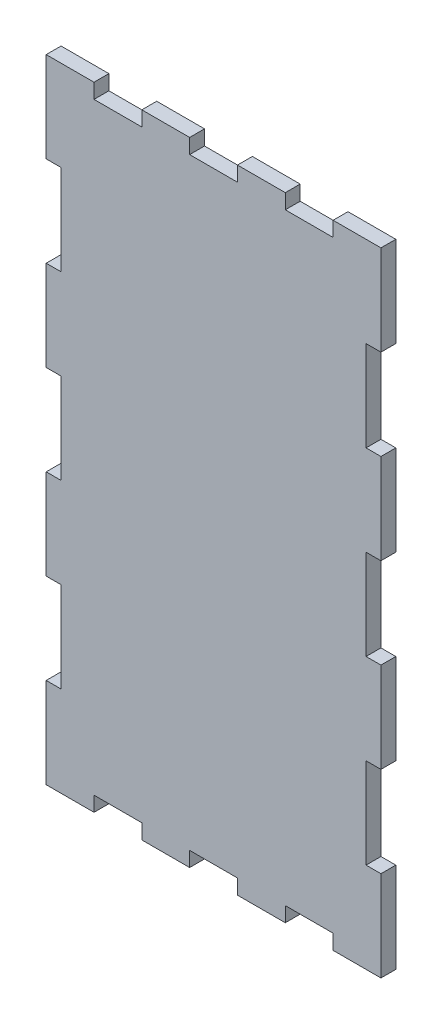
from build123d import *

# Parameters (mm, degrees)
BUITENAFMETING_RECHTHOEK_W  = 90
BUITENAFMETING_RECHTHOEK_H  = 170
PLAAT_DEPTH                 = 4
TAND_HOR_W                  = 12.857142857
TAND_HOR_H                  = 4
TAND_BOVEN_DEPTH            = 5
TANDEN_PATROON_BOVEN_COUNT  = 3
TANDEN_PATROON_BOVEN_PITCH  = 25.714285714
TAND_VER_W                  = 4
TAND_VER_H                  = 24.285714285
TAND_LINKS_DEPTH            = 5
TANDEN_PATROON_LINKS_COUNT  = 3
TANDEN_PATROON_LINKS_PITCH  = 48.571428571
TAND_O_W                    = 12.857142857
TAND_O_H                    = 4
TAND_ONDER_DEPTH            = 5
TANDEN_PATROON_ONDER_COUNT  = 3
TANDEN_PATROON_ONDER_PITCH  = 25.714285714
TAND_R_W                    = 4
TAND_R_H                    = 24.285714285
TAND_RECHTS_DEPTH           = 5
TANDEN_PATROON_RECHTS_COUNT = 3
TANDEN_PATROON_RECHTS_PITCH = 48.571428571


with BuildPart() as part:
    # Buitenafmeting Rechthoek → Plaat (new body)
    with BuildSketch(Plane.XY):
        with Locations((45, 85)):
            Rectangle(BUITENAFMETING_RECHTHOEK_W, BUITENAFMETING_RECHTHOEK_H)
    extrude(amount=-PLAAT_DEPTH)

    # Tand Hor → Tand Boven (cut, through all)
    with BuildSketch(Plane.XY):
        with Locations((19.285714286, 168)):
            Rectangle(TAND_HOR_W, TAND_HOR_H)
    tand_boven = extrude(amount=-TAND_BOVEN_DEPTH, mode=Mode.SUBTRACT)

    # Tanden Patroon Boven: Tand Boven ×3
    with Locations(*[(i * TANDEN_PATROON_BOVEN_PITCH, 0, 0) for i in range(1, TANDEN_PATROON_BOVEN_COUNT)]):
        add(tand_boven, mode=Mode.SUBTRACT)

    # Tand Ver → Tand Links (cut, through all)
    with BuildSketch(Plane.XY):
        with Locations((2, 133.571428572)):
            Rectangle(TAND_VER_W, TAND_VER_H)
    tand_links = extrude(amount=-TAND_LINKS_DEPTH, mode=Mode.SUBTRACT)

    # Tanden Patroon Links: Tand Links ×3
    with Locations(*[(0, -i * TANDEN_PATROON_LINKS_PITCH, 0) for i in range(1, TANDEN_PATROON_LINKS_COUNT)]):
        add(tand_links, mode=Mode.SUBTRACT)

    # Tand O → Tand Onder (cut, through all)
    with BuildSketch(Plane.XY):
        with Locations((19.285714286, 2)):
            Rectangle(TAND_O_W, TAND_O_H)
    tand_onder = extrude(amount=-TAND_ONDER_DEPTH, mode=Mode.SUBTRACT)

    # Tanden Patroon Onder: Tand Onder ×3
    with Locations(*[(i * TANDEN_PATROON_ONDER_PITCH, 0, 0) for i in range(1, TANDEN_PATROON_ONDER_COUNT)]):
        add(tand_onder, mode=Mode.SUBTRACT)

    # Tand R → Tand Rechts (cut, through all)
    with BuildSketch(Plane.XY):
        with Locations((88, 133.571428572)):
            Rectangle(TAND_R_W, TAND_R_H)
    tand_rechts = extrude(amount=-TAND_RECHTS_DEPTH, mode=Mode.SUBTRACT)

    # Tanden Patroon Rechts: Tand Rechts ×3
    with Locations(*[(0, -i * TANDEN_PATROON_RECHTS_PITCH, 0) for i in range(1, TANDEN_PATROON_RECHTS_COUNT)]):
        add(tand_rechts, mode=Mode.SUBTRACT)


solid = part.part
